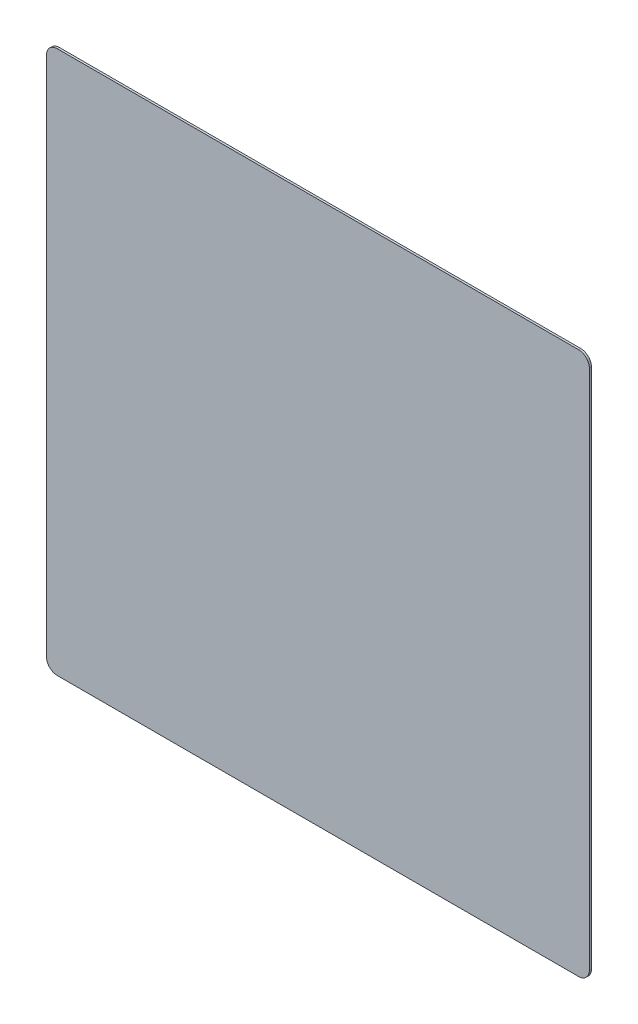
from build123d import *

# Parameters (mm, degrees)
SKETCH1_W           = 1010
SKETCH1_H           = 1010
BOSS_EXTRUDE1_DEPTH = 4
FILLET1_R           = 20


with BuildPart() as part:
    # Sketch1 → Boss-Extrude1 (new body)
    with BuildSketch(Plane.XY):
        Rectangle(SKETCH1_W, SKETCH1_H)
    extrude(amount=BOSS_EXTRUDE1_DEPTH)

    # Fillet1
    fillet1_edges = [part.edges().sort_by_distance(p)[0] for p in [
        (505, -505, 2),
        (-505, -505, 2),
        (-505, 505, 2),
        (505, 505, 2),
    ]]
    fillet(fillet1_edges, radius=FILLET1_R)


solid = part.part
